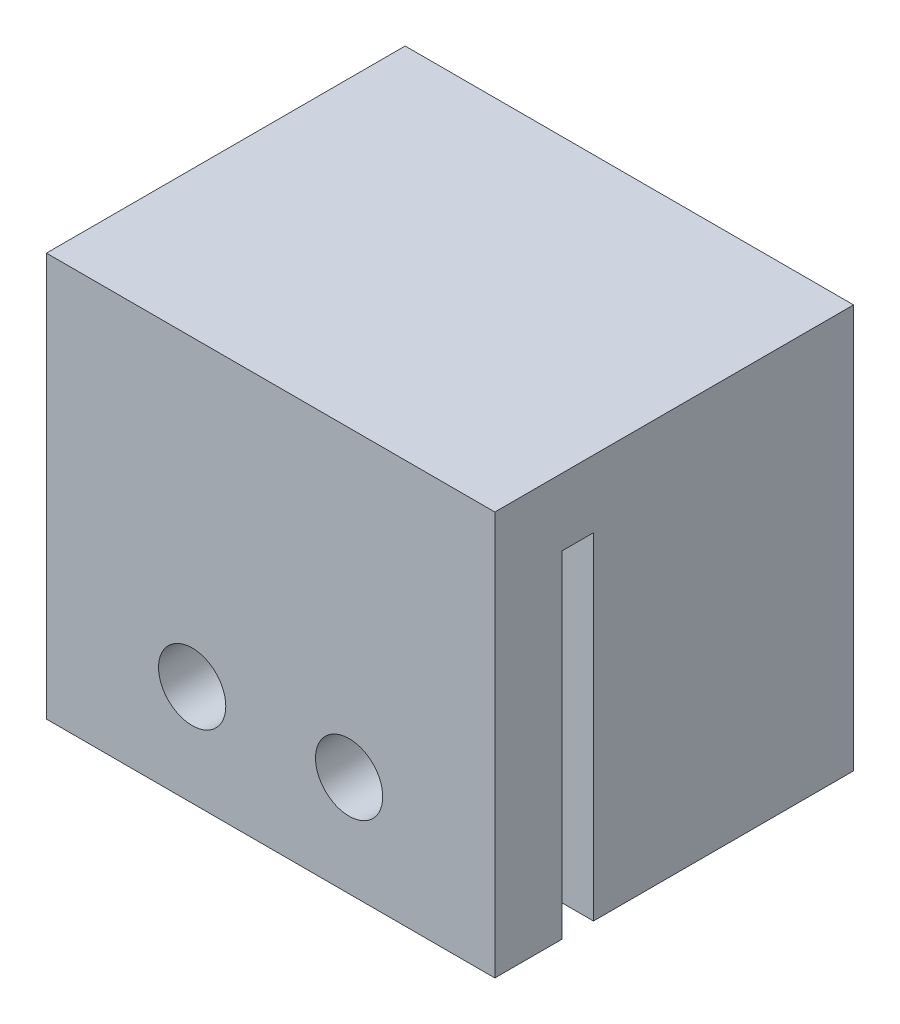
from build123d import *

# Parameters (mm, degrees)
CROQUIS1_W              = 20
CROQUIS1_H              = 18
SALIENTE_EXTRUIR1_DEPTH = 16
CROQUIS2_W              = 14.1
CROQUIS2_H              = 11.6
CORTAR_EXTRUIR1_DEPTH   = 9.05
CROQUIS4_W              = 20
CROQUIS4_H              = 1.4
CORTAR_EXTRUIR2_DEPTH   = 15
CROQUIS5_R              = 1.5
CORTAR_EXTRUIR3_DEPTH   = 17


with BuildPart() as part:
    # Croquis1 → Saliente-Extruir1 (new body)
    with BuildSketch(Plane.XY):
        Rectangle(CROQUIS1_W, CROQUIS1_H)
    extrude(amount=-SALIENTE_EXTRUIR1_DEPTH)

    # Croquis2 → Cortar-Extruir1 (cut)
    with BuildSketch(Plane.XZ.offset(9)):
        with Locations((0, -10.2)):
            Rectangle(CROQUIS2_W, CROQUIS2_H)
    extrude(amount=-CORTAR_EXTRUIR1_DEPTH, mode=Mode.SUBTRACT)

    # Croquis4 → Cortar-Extruir2 (cut)
    with BuildSketch(Plane.XZ.offset(9)):
        with Locations((0, -3.7)):
            Rectangle(CROQUIS4_W, CROQUIS4_H)
    extrude(amount=-CORTAR_EXTRUIR2_DEPTH, mode=Mode.SUBTRACT)

    # Croquis5 → Cortar-Extruir3 (cut, through all)
    with BuildSketch(Plane.XY):
        with Locations((-3.5, -4.5)):
            Circle(CROQUIS5_R)
        with Locations((3.5, -4.5)):
            Circle(CROQUIS5_R)
    extrude(amount=-CORTAR_EXTRUIR3_DEPTH, mode=Mode.SUBTRACT)


solid = part.part
